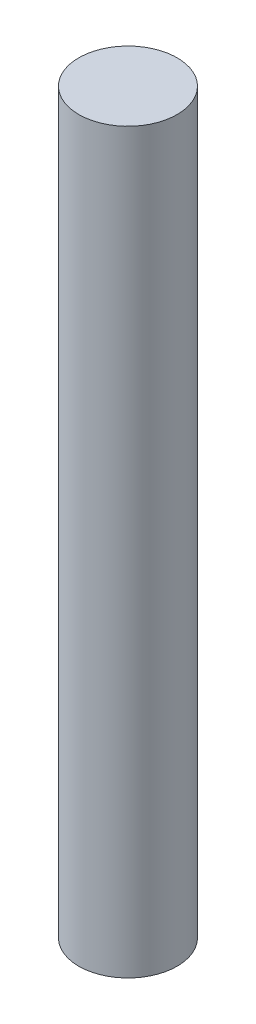
from build123d import *

# Parameters (mm, degrees)
SKETCH2_R           = 3
BOSS_EXTRUDE1_DEPTH = 45


with BuildPart() as part:
    # Sketch2 → Boss-Extrude1 (new body)
    with BuildSketch(Plane(origin=(0, 0, 0), x_dir=(1, 0, 0), z_dir=(0, 1, 0))):
        Circle(SKETCH2_R)
    extrude(amount=BOSS_EXTRUDE1_DEPTH)


solid = part.part
